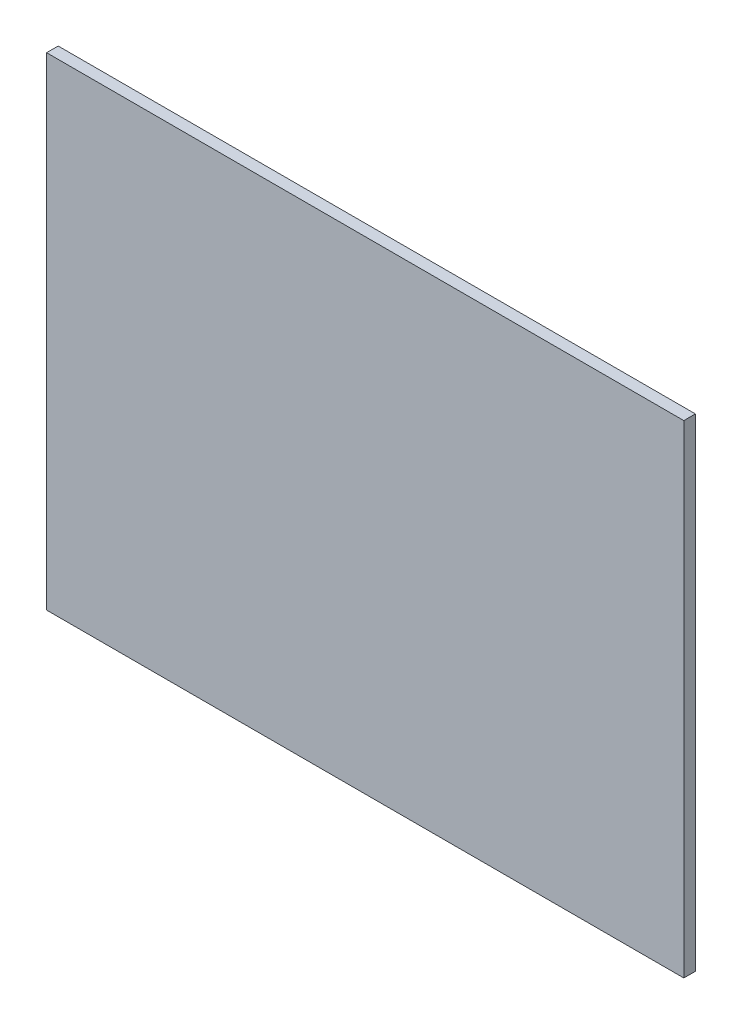
from build123d import *

# Parameters (mm, degrees)
ESQUISSE1_W        = 330
ESQUISSE1_H        = 250
BOSS_EXTRU_1_DEPTH = 6


with BuildPart() as part:
    # Esquisse1 → Boss.-Extru.1 (new body)
    with BuildSketch(Plane.XY):
        with Locations((35.763691323, 6.756756757)):
            Rectangle(ESQUISSE1_W, ESQUISSE1_H)
    extrude(amount=BOSS_EXTRU_1_DEPTH)


solid = part.part
